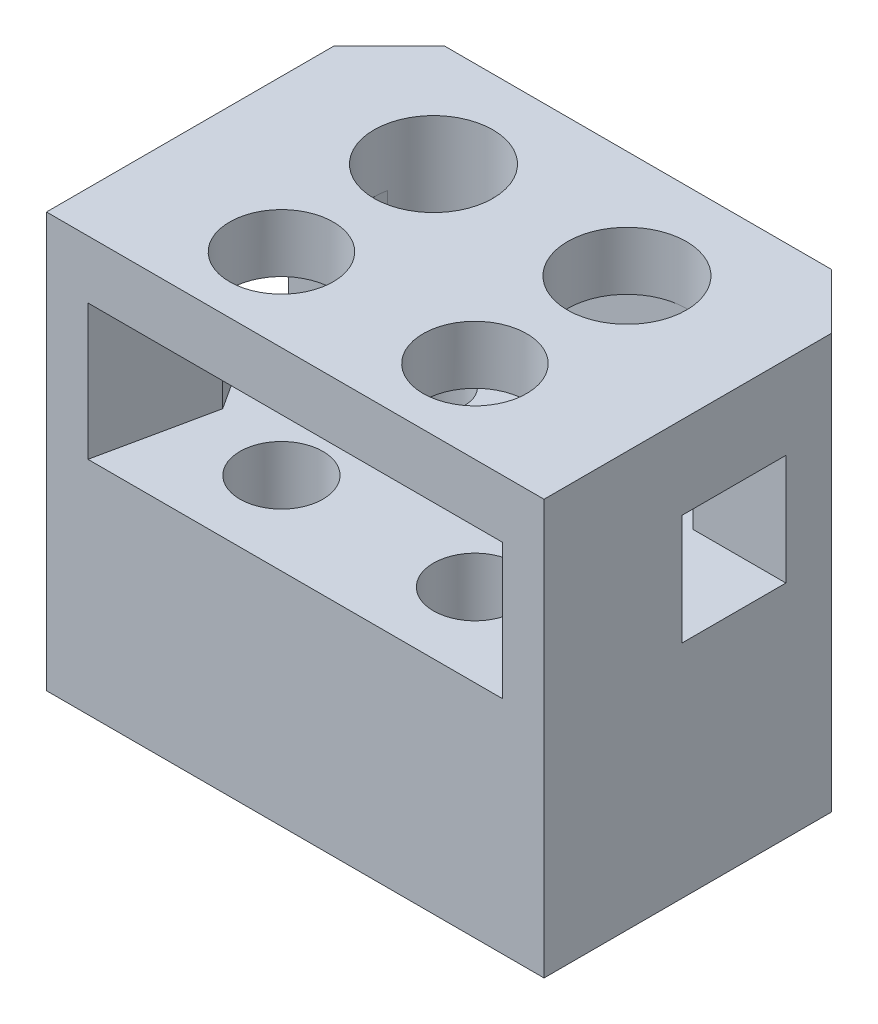
from build123d import *

# Parameters (mm, degrees)
BOSS_EXTRUDE1_DEPTH             = 30
CUT_EXTRUDE2_DEPTH              = 9.8
CBORE_FOR_M4_SBHCS1_D           = 4.5
CBORE_FOR_M4_SBHCS1_CBORE_D     = 8.6
CBORE_FOR_M4_SBHCS1_CBORE_DEPTH = 8
F_6_0_6_DIAMETER_HOLE1_D        = 6
SKETCH9_W                       = 7.5
SKETCH9_H                       = 8
CUT_EXTRUDE3_DEPTH              = 19
CUT_EXTRUDE3_DEPTH_BACK         = 19
CHAMFER1_SIZE2                  = 1.68681461
CHAMFER1_SIZE                   = 2
CHAMFER1_EDGE_2_SIZE2           = 1.68681461
CHAMFER1_EDGE_2_SIZE            = 2
F_7_5_7_5_DIAMETER_HOLE1_D      = 7.5
F_7_5_7_5_DIAMETER_HOLE1_DEPTH  = 7
F_7_5_7_5_DIAMETER_HOLE1_TIP    = 2.253227321


with BuildPart() as part:
    # Sketch1 → Boss-Extrude1 (new body)
    with BuildSketch(Plane(origin=(0, 0, 0), x_dir=(1, 0, 0), z_dir=(0, 1, 0))):
        Polygon((-18, 0), (18, 0), (18, 20.8), (14, 24.8), (-14, 24.8), (-18, 20.8), align=None)
    extrude(amount=BOSS_EXTRUDE1_DEPTH)

    # Sketch7 → Cut-Extrude2 (cut)
    with BuildSketch(Plane(origin=(0, 16, 0), x_dir=(1, 0, 0), z_dir=(0, 1, 0))):
        with BuildLine():
            Line((-7, 21.3), (7, 21.3))
            ThreePointArc((7, 21.3), (9.706928791, 20.34103824), (11.206489583, 17.891877451))
            Line((11.206489583, 17.891877451), (15, 0))
            Line((15, 0), (-15, 0))
            Line((-15, 0), (-11.206489583, 17.891877451))
            ThreePointArc((-11.206489583, 17.891877451), (-9.706928791, 20.34103824), (-7, 21.3))
        make_face()
    extrude(amount=CUT_EXTRUDE2_DEPTH, mode=Mode.SUBTRACT)

    # CBORE for M4 SBHCS1 (through all)
    with Locations(Plane(origin=(0, 30, 0), x_dir=(1, 0, 0), z_dir=(0, 1, 0))):
        with Locations((-7, 17), (7, 17)):
            CounterBoreHole(CBORE_FOR_M4_SBHCS1_D / 2, CBORE_FOR_M4_SBHCS1_CBORE_D / 2, CBORE_FOR_M4_SBHCS1_CBORE_DEPTH)

    # Ø6.0 (6) Diameter Hole1 (through all)
    with Locations(Plane(origin=(0, 30, 0), x_dir=(1, 0, 0), z_dir=(0, 1, 0))):
        with Locations((-7, 6), (7, 6)):
            Hole(F_6_0_6_DIAMETER_HOLE1_D / 2)

    # Sketch9 → Cut-Extrude3 (cut, two sides)
    with BuildSketch(Plane(origin=(0, 0, 0), x_dir=(0, 0, -1), z_dir=(1, 0, 0))) as cut_extrude3_sk:
        with Locations((13.75, 20)):
            Rectangle(SKETCH9_W, SKETCH9_H)
    extrude(amount=CUT_EXTRUDE3_DEPTH, mode=Mode.SUBTRACT)
    extrude(cut_extrude3_sk.sketch, amount=-CUT_EXTRUDE3_DEPTH_BACK, mode=Mode.SUBTRACT)

    # Chamfer1
    chamfer1_edges = [part.edges().sort_by_distance(p)[0] for p in [
        (-12.879758328, 20, -10),
    ]]
    chamfer(chamfer1_edges, length=CHAMFER1_SIZE, length2=CHAMFER1_SIZE2)

    # Chamfer1 edge 2
    chamfer1_edge_2_edges = [part.edges().sort_by_distance(p)[0] for p in [
        (12.879758328, 20, -10),
    ]]
    chamfer(chamfer1_edge_2_edges, length=CHAMFER1_EDGE_2_SIZE, length2=CHAMFER1_EDGE_2_SIZE2)

    # Ø7.5 (7.5) Diameter Hole1
    with Locations(Plane(origin=(0, 30, 0), x_dir=(1, 0, 0), z_dir=(0, 1, 0))):
        with Locations((-7, 6), (7, 6)):
            Hole(F_7_5_7_5_DIAMETER_HOLE1_D / 2, depth=F_7_5_7_5_DIAMETER_HOLE1_DEPTH)
            with Locations((0, 0, -(F_7_5_7_5_DIAMETER_HOLE1_DEPTH + F_7_5_7_5_DIAMETER_HOLE1_TIP / 2))):  # 118° drill point
                Cone(0, F_7_5_7_5_DIAMETER_HOLE1_D / 2, F_7_5_7_5_DIAMETER_HOLE1_TIP, mode=Mode.SUBTRACT)


solid = part.part
